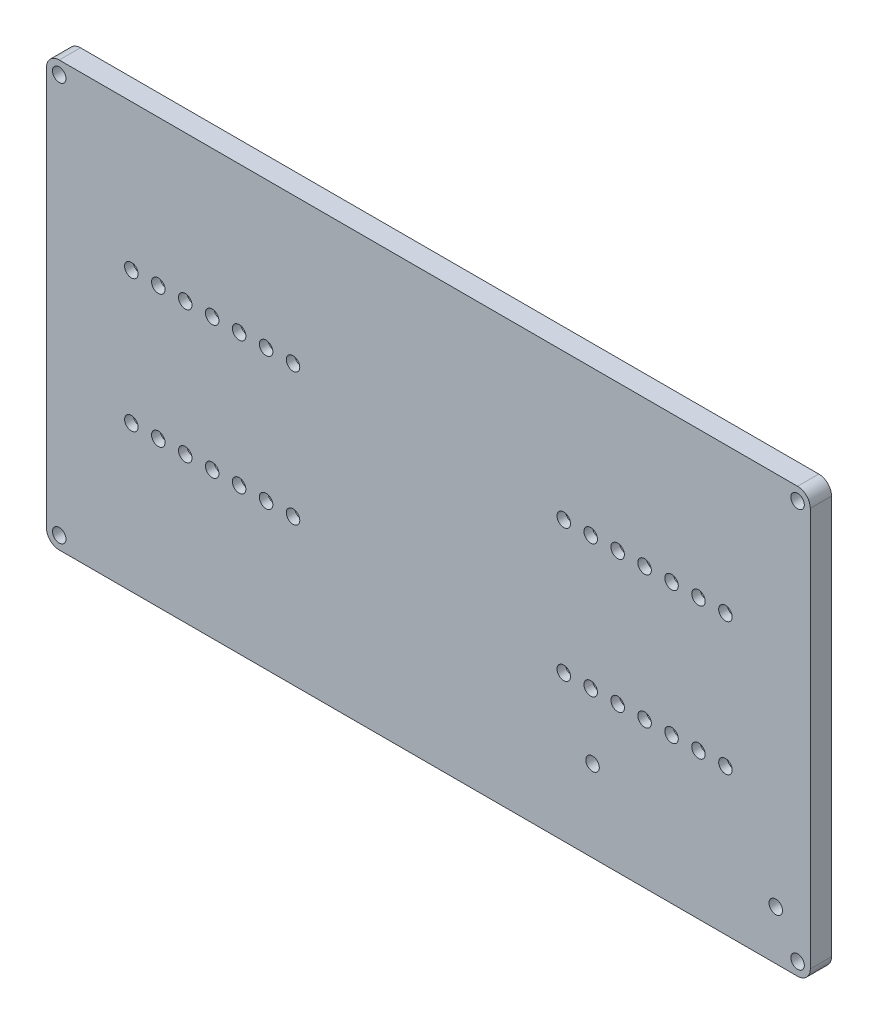
from build123d import *

# Parameters (mm, degrees)
SKETCH1_W                = 180
SKETCH1_H                = 100
BOSS_EXTRUDE1_DEPTH      = 5
SKETCH2_R                = 1.59
CUT_EXTRUDE1_DEPTH       = 6
LPATTERN1_COUNT          = 7
LPATTERN1_PITCH          = 6.35
LPATTERN1_COUNT_DIR2     = 2
LPATTERN1_PITCH_DIR2     = 31.24
MIRROR1_COPY_1_SKETCH_R  = 1.59
MIRROR1_COPY_1_DEPTH     = 6
MIRROR1_COPY_2_SKETCH_R  = 1.59
MIRROR1_COPY_2_DEPTH     = 6
MIRROR1_COPY_3_SKETCH_R  = 1.59
MIRROR1_COPY_3_DEPTH     = 6
MIRROR1_COPY_4_SKETCH_R  = 1.59
MIRROR1_COPY_4_DEPTH     = 6
MIRROR1_COPY_5_SKETCH_R  = 1.59
MIRROR1_COPY_5_DEPTH     = 6
MIRROR1_COPY_6_SKETCH_R  = 1.59
MIRROR1_COPY_6_DEPTH     = 6
MIRROR1_COPY_7_SKETCH_R  = 1.59
MIRROR1_COPY_7_DEPTH     = 6
MIRROR1_COPY_8_SKETCH_R  = 1.59
MIRROR1_COPY_8_DEPTH     = 6
MIRROR1_COPY_9_SKETCH_R  = 1.59
MIRROR1_COPY_9_DEPTH     = 6
MIRROR1_COPY_10_SKETCH_R = 1.59
MIRROR1_COPY_10_DEPTH    = 6
MIRROR1_COPY_11_SKETCH_R = 1.59
MIRROR1_COPY_11_DEPTH    = 6
MIRROR1_COPY_12_SKETCH_R = 1.59
MIRROR1_COPY_12_DEPTH    = 6
MIRROR1_COPY_13_SKETCH_R = 1.59
MIRROR1_COPY_13_DEPTH    = 6
SKETCH4_W                = 44.1
SKETCH4_H                = 5.2
CUT_EXTRUDE3_DEPTH       = 3
MIRROR5_COPY_1_SKETCH_W  = 44.1
MIRROR5_COPY_1_SKETCH_H  = 5.2
MIRROR5_COPY_1_DEPTH     = 3
FILLET1_R                = 1
FILLET2_R                = 3
SKETCH5_R                = 3
BOSS_EXTRUDE3_DEPTH      = 3
SKETCH11_R               = 1.59
CUT_EXTRUDE5_DEPTH       = 1
CUT_EXTRUDE5_DEPTH_BACK  = 9
SKETCH12_R               = 1.59
CUT_EXTRUDE6_DEPTH       = 4
CUT_EXTRUDE6_DEPTH_BACK  = 6
SKETCH14_R               = 3
CUT_EXTRUDE7_DEPTH       = 4


with BuildPart() as part:
    # Sketch1 → Boss-Extrude1 (new body)
    with BuildSketch(Plane.XY):
        Rectangle(SKETCH1_W, SKETCH1_H)
    extrude(amount=BOSS_EXTRUDE1_DEPTH)

    # Sketch2 → Cut-Extrude1 (cut, through all)
    with BuildSketch(Plane.XY.offset(5)):
        with Locations((-70, 15.62)):
            Circle(SKETCH2_R)
    cut_extrude1 = extrude(amount=-CUT_EXTRUDE1_DEPTH, mode=Mode.SUBTRACT)

    # LPattern1: Cut-Extrude1 7 × 2
    with Locations(*[(i * LPATTERN1_PITCH, -j * LPATTERN1_PITCH_DIR2, 0) for i in range(LPATTERN1_COUNT) for j in range(LPATTERN1_COUNT_DIR2) if (i, j) != (0, 0)]):
        add(cut_extrude1, mode=Mode.SUBTRACT)

    # Mirror1: Cut-Extrude1 across plane
    add(cut_extrude1.mirror(Plane(origin=(0, 0, 0), x_dir=(0, 0, 1), z_dir=(1, 0, 0))), mode=Mode.SUBTRACT)

    # Mirror1 copy 1 sketch → Mirror1 copy 1 (cut, through all)
    with BuildSketch(Plane(origin=(0, -31.24, 5), x_dir=(-1, 0, 0), z_dir=(0, 0, 1))):
        with Locations((-70, -15.62)):
            Circle(MIRROR1_COPY_1_SKETCH_R)
    extrude(amount=-MIRROR1_COPY_1_DEPTH, mode=Mode.SUBTRACT)

    # Mirror1 copy 2 sketch → Mirror1 copy 2 (cut, through all)
    with BuildSketch(Plane(origin=(-6.35, 0, 5), x_dir=(-1, 0, 0), z_dir=(0, 0, 1))):
        with Locations((-70, -15.62)):
            Circle(MIRROR1_COPY_2_SKETCH_R)
    extrude(amount=-MIRROR1_COPY_2_DEPTH, mode=Mode.SUBTRACT)

    # Mirror1 copy 3 sketch → Mirror1 copy 3 (cut, through all)
    with BuildSketch(Plane(origin=(-6.35, -31.24, 5), x_dir=(-1, 0, 0), z_dir=(0, 0, 1))):
        with Locations((-70, -15.62)):
            Circle(MIRROR1_COPY_3_SKETCH_R)
    extrude(amount=-MIRROR1_COPY_3_DEPTH, mode=Mode.SUBTRACT)

    # Mirror1 copy 4 sketch → Mirror1 copy 4 (cut, through all)
    with BuildSketch(Plane(origin=(-12.7, 0, 5), x_dir=(-1, 0, 0), z_dir=(0, 0, 1))):
        with Locations((-70, -15.62)):
            Circle(MIRROR1_COPY_4_SKETCH_R)
    extrude(amount=-MIRROR1_COPY_4_DEPTH, mode=Mode.SUBTRACT)

    # Mirror1 copy 5 sketch → Mirror1 copy 5 (cut, through all)
    with BuildSketch(Plane(origin=(-12.7, -31.24, 5), x_dir=(-1, 0, 0), z_dir=(0, 0, 1))):
        with Locations((-70, -15.62)):
            Circle(MIRROR1_COPY_5_SKETCH_R)
    extrude(amount=-MIRROR1_COPY_5_DEPTH, mode=Mode.SUBTRACT)

    # Mirror1 copy 6 sketch → Mirror1 copy 6 (cut, through all)
    with BuildSketch(Plane(origin=(-19.05, 0, 5), x_dir=(-1, 0, 0), z_dir=(0, 0, 1))):
        with Locations((-70, -15.62)):
            Circle(MIRROR1_COPY_6_SKETCH_R)
    extrude(amount=-MIRROR1_COPY_6_DEPTH, mode=Mode.SUBTRACT)

    # Mirror1 copy 7 sketch → Mirror1 copy 7 (cut, through all)
    with BuildSketch(Plane(origin=(-19.05, -31.24, 5), x_dir=(-1, 0, 0), z_dir=(0, 0, 1))):
        with Locations((-70, -15.62)):
            Circle(MIRROR1_COPY_7_SKETCH_R)
    extrude(amount=-MIRROR1_COPY_7_DEPTH, mode=Mode.SUBTRACT)

    # Mirror1 copy 8 sketch → Mirror1 copy 8 (cut, through all)
    with BuildSketch(Plane(origin=(-25.4, 0, 5), x_dir=(-1, 0, 0), z_dir=(0, 0, 1))):
        with Locations((-70, -15.62)):
            Circle(MIRROR1_COPY_8_SKETCH_R)
    extrude(amount=-MIRROR1_COPY_8_DEPTH, mode=Mode.SUBTRACT)

    # Mirror1 copy 9 sketch → Mirror1 copy 9 (cut, through all)
    with BuildSketch(Plane(origin=(-25.4, -31.24, 5), x_dir=(-1, 0, 0), z_dir=(0, 0, 1))):
        with Locations((-70, -15.62)):
            Circle(MIRROR1_COPY_9_SKETCH_R)
    extrude(amount=-MIRROR1_COPY_9_DEPTH, mode=Mode.SUBTRACT)

    # Mirror1 copy 10 sketch → Mirror1 copy 10 (cut, through all)
    with BuildSketch(Plane(origin=(-31.75, 0, 5), x_dir=(-1, 0, 0), z_dir=(0, 0, 1))):
        with Locations((-70, -15.62)):
            Circle(MIRROR1_COPY_10_SKETCH_R)
    extrude(amount=-MIRROR1_COPY_10_DEPTH, mode=Mode.SUBTRACT)

    # Mirror1 copy 11 sketch → Mirror1 copy 11 (cut, through all)
    with BuildSketch(Plane(origin=(-31.75, -31.24, 5), x_dir=(-1, 0, 0), z_dir=(0, 0, 1))):
        with Locations((-70, -15.62)):
            Circle(MIRROR1_COPY_11_SKETCH_R)
    extrude(amount=-MIRROR1_COPY_11_DEPTH, mode=Mode.SUBTRACT)

    # Mirror1 copy 12 sketch → Mirror1 copy 12 (cut, through all)
    with BuildSketch(Plane(origin=(-38.1, 0, 5), x_dir=(-1, 0, 0), z_dir=(0, 0, 1))):
        with Locations((-70, -15.62)):
            Circle(MIRROR1_COPY_12_SKETCH_R)
    extrude(amount=-MIRROR1_COPY_12_DEPTH, mode=Mode.SUBTRACT)

    # Mirror1 copy 13 sketch → Mirror1 copy 13 (cut, through all)
    with BuildSketch(Plane(origin=(-38.1, -31.24, 5), x_dir=(-1, 0, 0), z_dir=(0, 0, 1))):
        with Locations((-70, -15.62)):
            Circle(MIRROR1_COPY_13_SKETCH_R)
    extrude(amount=-MIRROR1_COPY_13_DEPTH, mode=Mode.SUBTRACT)

    # Sketch4 → Cut-Extrude3 (cut)
    with BuildSketch(Plane(origin=(0, 0, 0), x_dir=(-1, 0, 0), z_dir=(0, 0, -1))):
        with Locations((50.95, 15.62)):
            Rectangle(SKETCH4_W, SKETCH4_H)
    cut_extrude3 = extrude(amount=-CUT_EXTRUDE3_DEPTH, mode=Mode.SUBTRACT)

    # Mirror4: Cut-Extrude3 across plane
    add(cut_extrude3.mirror(Plane.ZX), mode=Mode.SUBTRACT)

    # Mirror5: Cut-Extrude3 across plane
    add(cut_extrude3.mirror(Plane(origin=(0, 0, 0), x_dir=(0, 0, 1), z_dir=(1, 0, 0))), mode=Mode.SUBTRACT)

    # Mirror5 copy 1 sketch → Mirror5 copy 1 (cut)
    with BuildSketch(Plane(origin=(0, 0, 0), x_dir=(1, 0, 0), z_dir=(0, 0, -1))):
        with Locations((50.95, 15.62)):
            Rectangle(MIRROR5_COPY_1_SKETCH_W, MIRROR5_COPY_1_SKETCH_H)
    extrude(amount=-MIRROR5_COPY_1_DEPTH, mode=Mode.SUBTRACT)

    # Fillet1
    fillet1_edges = [part.edges().sort_by_distance(p)[0] for p in [
        (-28.9, 13.02, 1.5),
        (-28.9, 18.22, 1.5),
        (-73, 18.22, 1.5),
        (-73, 13.02, 1.5),
        (-28.9, -18.22, 1.5),
        (-28.9, -13.02, 1.5),
        (-73, -13.02, 1.5),
        (-73, -18.22, 1.5),
        (28.9, -13.02, 1.5),
        (28.9, -18.22, 1.5),
        (73, -18.22, 1.5),
        (73, -13.02, 1.5),
        (28.9, 18.22, 1.5),
        (28.9, 13.02, 1.5),
        (73, 13.02, 1.5),
        (73, 18.22, 1.5),
    ]]
    fillet(fillet1_edges, radius=FILLET1_R)

    # Fillet2
    fillet2_edges = [part.edges().sort_by_distance(p)[0] for p in [
        (-90, 50, 2.5),
        (90, 50, 2.5),
        (90, -50, 2.5),
        (-90, -50, 2.5),
    ]]
    fillet(fillet2_edges, radius=FILLET2_R)

    # Sketch5 → Boss-Extrude3 (add)
    with BuildSketch(Plane(origin=(0, 0, 0), x_dir=(-1, 0, 0), z_dir=(0, 0, -1))):
        with Locations((-81.863597073, -38.398306499)):
            Circle(SKETCH5_R)
        with Locations((-38.683597073, -30.778306499)):
            Circle(SKETCH5_R)
    extrude(amount=BOSS_EXTRUDE3_DEPTH)

    # Sketch11 → Cut-Extrude5 (cut, two sides)
    with BuildSketch(Plane(origin=(0, 0, -3), x_dir=(-1, 0, 0), z_dir=(0, 0, -1))) as cut_extrude5_sk:
        with Locations((-81.863597073, -38.398306499)):
            Circle(SKETCH11_R)
        with Locations((-38.683597073, -30.778306499)):
            Circle(SKETCH11_R)
    extrude(amount=CUT_EXTRUDE5_DEPTH, mode=Mode.SUBTRACT)
    extrude(cut_extrude5_sk.sketch, amount=-CUT_EXTRUDE5_DEPTH_BACK, mode=Mode.SUBTRACT)

    # Sketch12 → Cut-Extrude6 (cut, two sides)
    with BuildSketch(Plane(origin=(0, 0, 0), x_dir=(-1, 0, 0), z_dir=(0, 0, -1))) as cut_extrude6_sk:
        with Locations((-87, -47)):
            Circle(SKETCH12_R)
        with Locations((-87, 47)):
            Circle(SKETCH12_R)
        with Locations((87, 47)):
            Circle(SKETCH12_R)
        with Locations((87, -47)):
            Circle(SKETCH12_R)
    extrude(amount=CUT_EXTRUDE6_DEPTH, mode=Mode.SUBTRACT)
    extrude(cut_extrude6_sk.sketch, amount=-CUT_EXTRUDE6_DEPTH_BACK, mode=Mode.SUBTRACT)

    # Sketch14 → Cut-Extrude7 (cut)
    with BuildSketch(Plane(origin=(0, 0, 0), x_dir=(-1, 0, 0), z_dir=(0, 0, -1))):
        with BuildLine():
            ThreePointArc((-85.348265181, 49), (-84.514110663, 47.740663297), (-84.522995338, 46.230145586))
            Line((-84.522995338, 46.230145586), (-34.525491807, 19.22))
            Line((-34.525491807, 19.22), (-29.9, 19.22))
            ThreePointArc((-29.9, 19.22), (-28.485786438, 18.634213562), (-27.9, 17.22))
            Line((-27.9, 17.22), (-27.9, 15.640711323))
            Line((-27.9, 15.640711323), (-0.79625872, 0.998460287))
            Line((-0.79625872, 0.998460287), (0.796309268, 0.998487594))
            Line((0.796309268, 0.998487594), (27.9, 15.640711323))
            Line((27.9, 15.640711323), (27.9, 17.22))
            ThreePointArc((27.9, 17.22), (28.485786438, 18.634213562), (29.9, 19.22))
            Line((29.9, 19.22), (34.525491807, 19.22))
            Line((34.525491807, 19.22), (84.526476888, 46.232026423))
            ThreePointArc((84.526476888, 46.232026423), (84.518614054, 47.742175039), (85.354369422, 49))
            Line((85.354369422, 49), (-85.348265181, 49))
        make_face()
        with BuildLine():
            Line((36.62940181, -19.22), (85.00178239, -45.352205601))
            ThreePointArc((85.00178239, -45.352205601), (87.001401699, -44.410000379), (89, -45.354369422))
            Line((89, -45.354369422), (89, -1))
            Line((89, -1), (2.905751439, -1.001476236))
            Line((2.905751439, -1.001476236), (27.9, -14.504116263))
            Line((27.9, -14.504116263), (27.9, -14.02))
            ThreePointArc((27.9, -14.02), (28.485786438, -12.605786438), (29.9, -12.02))
            Line((29.9, -12.02), (72, -12.02))
            ThreePointArc((72, -12.02), (73.414213562, -12.605786438), (74, -14.02))
            Line((74, -14.02), (74, -17.22))
            ThreePointArc((74, -17.22), (73.414213562, -18.634213562), (72, -19.22))
            Line((72, -19.22), (36.62940181, -19.22))
        make_face()
        with BuildLine():
            ThreePointArc((89, 45.354369422), (87.001401699, 44.410000379), (85.00178239, 45.352205601))
            Line((85.00178239, 45.352205601), (36.62940181, 19.22))
            Line((36.62940181, 19.22), (72, 19.22))
            ThreePointArc((72, 19.22), (73.414213562, 18.634213562), (74, 17.22))
            Line((74, 17.22), (74, 14.02))
            ThreePointArc((74, 14.02), (73.414213562, 12.605786438), (72, 12.02))
            Line((72, 12.02), (29.9, 12.02))
            ThreePointArc((29.9, 12.02), (28.485786438, 12.605786438), (27.9, 14.02))
            Line((27.9, 14.02), (27.9, 14.504116263))
            Line((27.9, 14.504116263), (2.900286051, 0.99852367))
            Line((2.900286051, 0.99852367), (89, 1))
            Line((89, 1), (89, 45.354369422))
        make_face()
        with BuildLine():
            Line((-2.9059359, -1.001575888), (-89, -1.003052121))
            Line((-89, -1.003052121), (-89, -45.354369422))
            ThreePointArc((-89, -45.354369422), (-87.001401699, -44.410000379), (-85.00178239, -45.352205601))
            Line((-85.00178239, -45.352205601), (-36.62940181, -19.22))
            Line((-36.62940181, -19.22), (-72, -19.22))
            ThreePointArc((-72, -19.22), (-73.414213562, -18.634213562), (-74, -17.22))
            Line((-74, -17.22), (-74, -14.02))
            ThreePointArc((-74, -14.02), (-73.414213562, -12.605786438), (-72, -12.02))
            Line((-72, -12.02), (-29.9, -12.02))
            ThreePointArc((-29.9, -12.02), (-28.485786438, -12.605786438), (-27.9, -14.02))
            Line((-27.9, -14.02), (-27.9, -14.504116263))
            Line((-27.9, -14.504116263), (-2.9059359, -1.001575888))
        make_face()
        with Locations((-81.863597073, -38.398306499)):
            Circle(SKETCH14_R, mode=Mode.SUBTRACT)
        with BuildLine():
            Line((-34.525491807, -19.22), (-84.526476888, -46.232026423))
            ThreePointArc((-84.526476888, -46.232026423), (-84.518614054, -47.742175039), (-85.354369422, -49))
            Line((-85.354369422, -49), (85.354369422, -49))
            ThreePointArc((85.354369422, -49), (84.518614054, -47.742175039), (84.526476888, -46.232026423))
            Line((84.526476888, -46.232026423), (34.525491807, -19.22))
            Line((34.525491807, -19.22), (29.9, -19.22))
            ThreePointArc((29.9, -19.22), (28.485786438, -18.634213562), (27.9, -17.22))
            Line((27.9, -17.22), (27.9, -15.640711323))
            Line((27.9, -15.640711323), (0.801908211, -1.00151231))
            Line((0.801908211, -1.00151231), (-0.801959117, -1.001539811))
            Line((-0.801959117, -1.001539811), (-27.9, -15.640711323))
            Line((-27.9, -15.640711323), (-27.9, -17.22))
            ThreePointArc((-27.9, -17.22), (-28.485786438, -18.634213562), (-29.9, -19.22))
            Line((-29.9, -19.22), (-34.525491807, -19.22))
        make_face()
        with Locations((-38.683597073, -30.778306499)):
            Circle(SKETCH14_R, mode=Mode.SUBTRACT)
        with BuildLine():
            ThreePointArc((-84.99830084, 45.350324763), (-86.998664988, 44.406117556), (-89, 45.348265181))
            Line((-89, 45.348265181), (-89, 0.99694788))
            Line((-89, 0.99694788), (-2.900101948, 0.998424213))
            Line((-2.900101948, 0.998424213), (-27.9, 14.504116263))
            Line((-27.9, 14.504116263), (-27.9, 14.02))
            ThreePointArc((-27.9, 14.02), (-28.485786438, 12.605786438), (-29.9, 12.02))
            Line((-29.9, 12.02), (-72, 12.02))
            ThreePointArc((-72, 12.02), (-73.414213562, 12.605786438), (-74, 14.02))
            Line((-74, 14.02), (-74, 17.22))
            ThreePointArc((-74, 17.22), (-73.414213562, 18.634213562), (-72, 19.22))
            Line((-72, 19.22), (-36.62940181, 19.22))
            Line((-36.62940181, 19.22), (-84.99830084, 45.350324763))
        make_face()
    extrude(amount=-CUT_EXTRUDE7_DEPTH, mode=Mode.SUBTRACT)


solid = part.part
